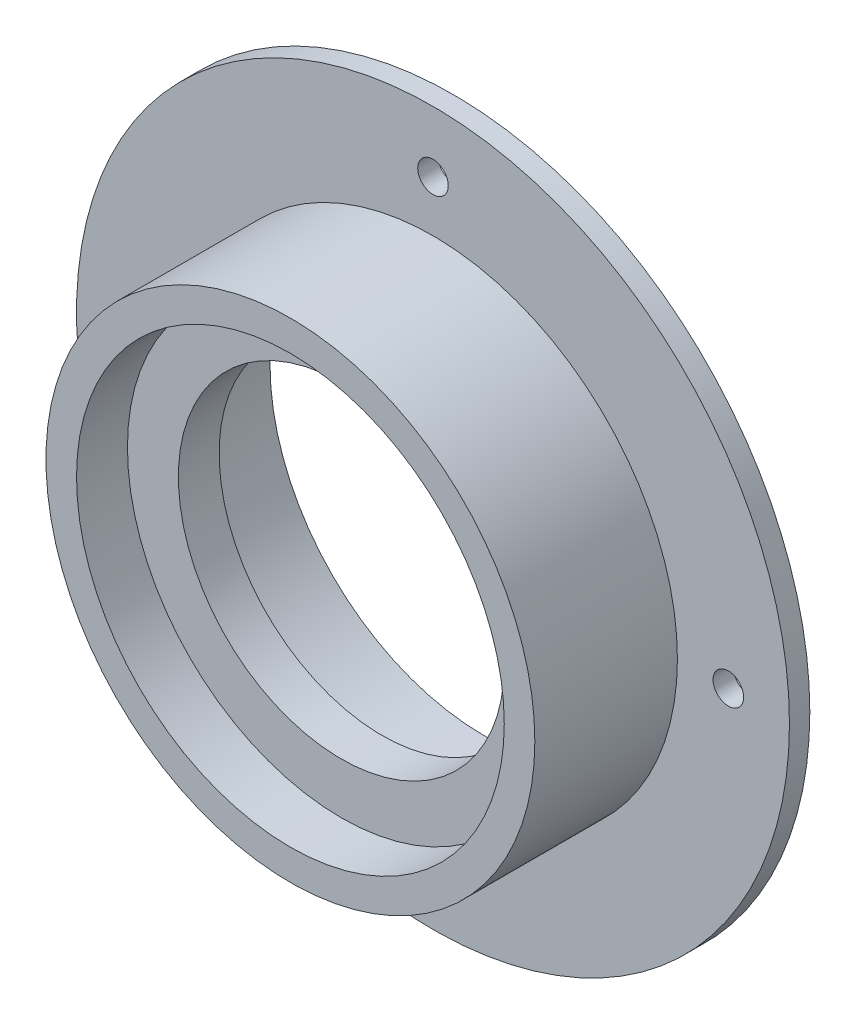
from build123d import *
from build123d.topology import SkipClean

# Parameters (mm, degrees)
SKETCH1_R           = 35
BOSS_EXTRUDE1_DEPTH = 2
SKETCH2_R           = 24
SKETCH2_R_2         = 21
BOSS_EXTRUDE2_DEPTH = 14
SKETCH3_R           = 21
CUT_EXTRUDE1_DEPTH  = 10
CUT_EXTRUDE2_REACH  = 54.019
SKETCH4_R           = 1.5
BOSS_EXTRUDE3_START = -5
SKETCH5_R           = 21
SKETCH5_R_2         = 16
BOSS_EXTRUDE3_DEPTH = 4
SKETCH6_R           = 24
SKETCH6_R_2         = 21
BOSS_EXTRUDE4_DEPTH = 3


with BuildPart() as part:
    # Sketch1 → Boss-Extrude1 (new body)
    with BuildSketch(Plane.XY):
        Circle(SKETCH1_R)
    extrude(amount=BOSS_EXTRUDE1_DEPTH)

    # Sketch2 → Boss-Extrude2 (add)
    with BuildSketch(Plane.XY.offset(2)):
        Circle(SKETCH2_R)
        Circle(SKETCH2_R_2, mode=Mode.SUBTRACT)
    extrude(amount=BOSS_EXTRUDE2_DEPTH)

    # Sketch3 → Cut-Extrude1 (cut)
    with BuildSketch(Plane.XY.offset(2)):
        Circle(SKETCH3_R)
    extrude(amount=-CUT_EXTRUDE1_DEPTH, mode=Mode.SUBTRACT)

    # Sketch4 → Cut-Extrude2 (cut, up to next)
    with BuildSketch(Plane(origin=(0, 0, 0), x_dir=(-1, 0, 0), z_dir=(0, 0, -1)), mode=Mode.PRIVATE) as cut_extrude2_sk1:
        with Locations((29, 0)):
            Circle(SKETCH4_R)
    cut_extrude2_tool1 = extrude(cut_extrude2_sk1.sketch, amount=-CUT_EXTRUDE2_REACH, mode=Mode.PRIVATE) & part.part
    # Sketch4 → Cut-Extrude2 (cut, up to next)
    with BuildSketch(Plane(origin=(0, 0, 0), x_dir=(-1, 0, 0), z_dir=(0, 0, -1)), mode=Mode.PRIVATE) as cut_extrude2_sk2:
        with Locations((0, -29)):
            Circle(SKETCH4_R)
    cut_extrude2_tool2 = extrude(cut_extrude2_sk2.sketch, amount=-CUT_EXTRUDE2_REACH, mode=Mode.PRIVATE) & part.part
    # Sketch4 → Cut-Extrude2 (cut, up to next)
    with BuildSketch(Plane(origin=(0, 0, 0), x_dir=(-1, 0, 0), z_dir=(0, 0, -1)), mode=Mode.PRIVATE) as cut_extrude2_sk3:
        with Locations((-29, 0)):
            Circle(SKETCH4_R)
    cut_extrude2_tool3 = extrude(cut_extrude2_sk3.sketch, amount=-CUT_EXTRUDE2_REACH, mode=Mode.PRIVATE) & part.part
    # Sketch4 → Cut-Extrude2 (cut, up to next)
    with BuildSketch(Plane(origin=(0, 0, 0), x_dir=(-1, 0, 0), z_dir=(0, 0, -1)), mode=Mode.PRIVATE) as cut_extrude2_sk4:
        with Locations((0, 29)):
            Circle(SKETCH4_R)
    cut_extrude2_tool4 = extrude(cut_extrude2_sk4.sketch, amount=-CUT_EXTRUDE2_REACH, mode=Mode.PRIVATE) & part.part
    add(cut_extrude2_tool1.solids().sort_by_distance((-29, 0, 0))[0], mode=Mode.SUBTRACT)
    add(cut_extrude2_tool2.solids().sort_by_distance((0, -29, 0))[0], mode=Mode.SUBTRACT)
    add(cut_extrude2_tool3.solids().sort_by_distance((29, 0, 0))[0], mode=Mode.SUBTRACT)
    add(cut_extrude2_tool4.solids().sort_by_distance((0, 29, 0))[0], mode=Mode.SUBTRACT)

    # Sketch5 → Boss-Extrude3 (add)
    with BuildSketch(Plane.XY.offset(16).offset(BOSS_EXTRUDE3_START)):
        Circle(SKETCH5_R)
        Circle(SKETCH5_R_2, mode=Mode.SUBTRACT)
    extrude(amount=-BOSS_EXTRUDE3_DEPTH)

    # Sketch6 → Boss-Extrude4 (add)
    with SkipClean():  # the faces are left unmerged after this step: merging them gives an invalid solid
        with BuildSketch(Plane(origin=(0, 0, 0), x_dir=(-1, 0, 0), z_dir=(0, 0, -1))):
            with Locations(Location((0, 0, 0), (0, 0, 180))):
                Circle(SKETCH6_R)
            Circle(SKETCH6_R_2, mode=Mode.SUBTRACT)
        extrude(amount=BOSS_EXTRUDE4_DEPTH)


solid = part.part
